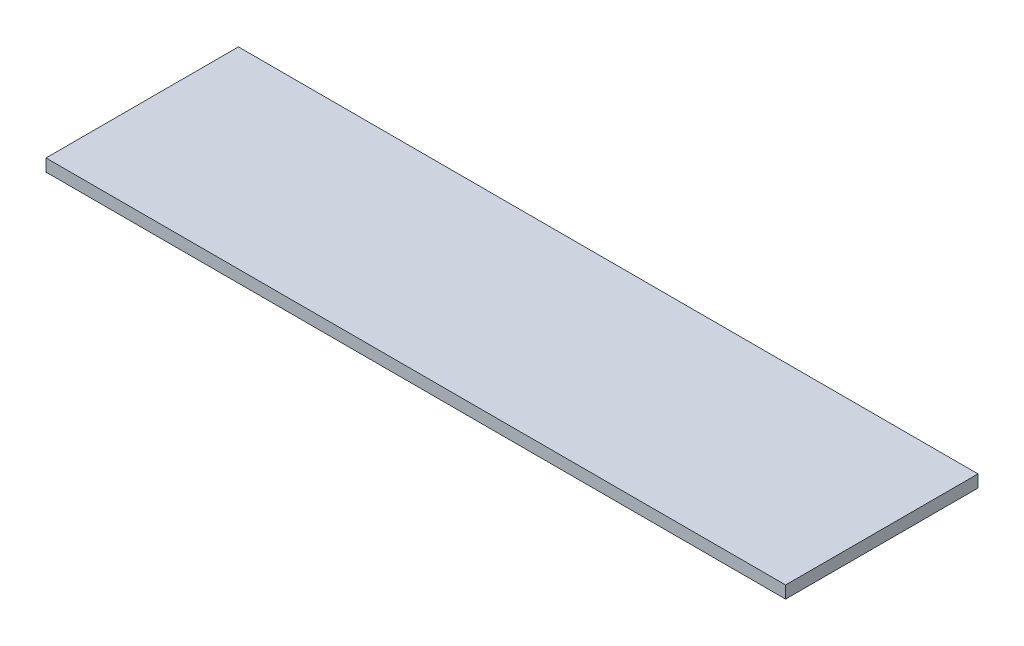
from build123d import *

# Parameters (mm, degrees)
SKETCH_1_W      = 1084
SKETCH_1_H      = 282
EXTRUDE_1_DEPTH = 18


with BuildPart() as part:
    # Эскиз1 → Бобышка-Вытянуть1 (new body)
    with BuildSketch(Plane(origin=(0, 0, 0), x_dir=(1, 0, 0), z_dir=(0, 1, 0))):
        Rectangle(SKETCH_1_W, SKETCH_1_H)
    extrude(amount=EXTRUDE_1_DEPTH)


solid = part.part
